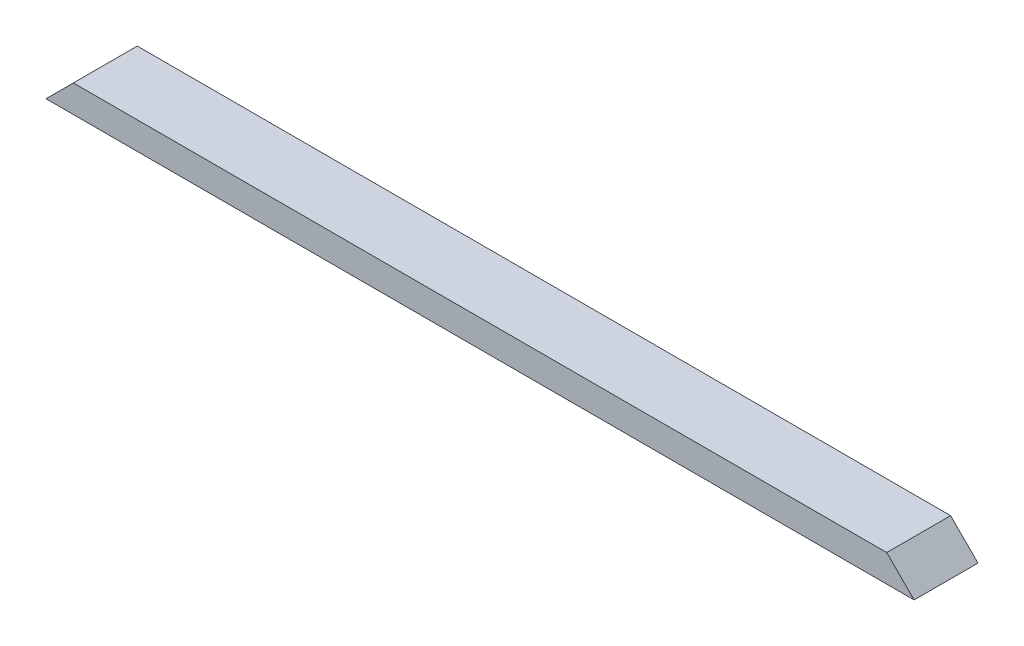
from build123d import *

# Parameters (mm, degrees)
SKETCH1_W           = 1208.0875
SKETCH1_H           = 88.9
BOSS_EXTRUDE1_DEPTH = 38.1
CUT_EXTRUDE1_DEPTH  = 89.9


with BuildPart() as part:
    # Sketch1 → Boss-Extrude1 (new body)
    with BuildSketch(Plane(origin=(0, 0, 0), x_dir=(1, 0, 0), z_dir=(0, 1, 0))):
        with Locations((604.04375, 44.45)):
            Rectangle(SKETCH1_W, SKETCH1_H)
    extrude(amount=BOSS_EXTRUDE1_DEPTH)

    # Sketch2 → Cut-Extrude1 (cut, through all)
    with BuildSketch(Plane.XY):
        Polygon((0, 0), (38.1, 38.1), (0, 38.1), align=None)
        Polygon((1208.0875, 0), (1208.0875, 38.1), (1169.9875, 38.1), align=None)
    extrude(amount=-CUT_EXTRUDE1_DEPTH, mode=Mode.SUBTRACT)


solid = part.part
